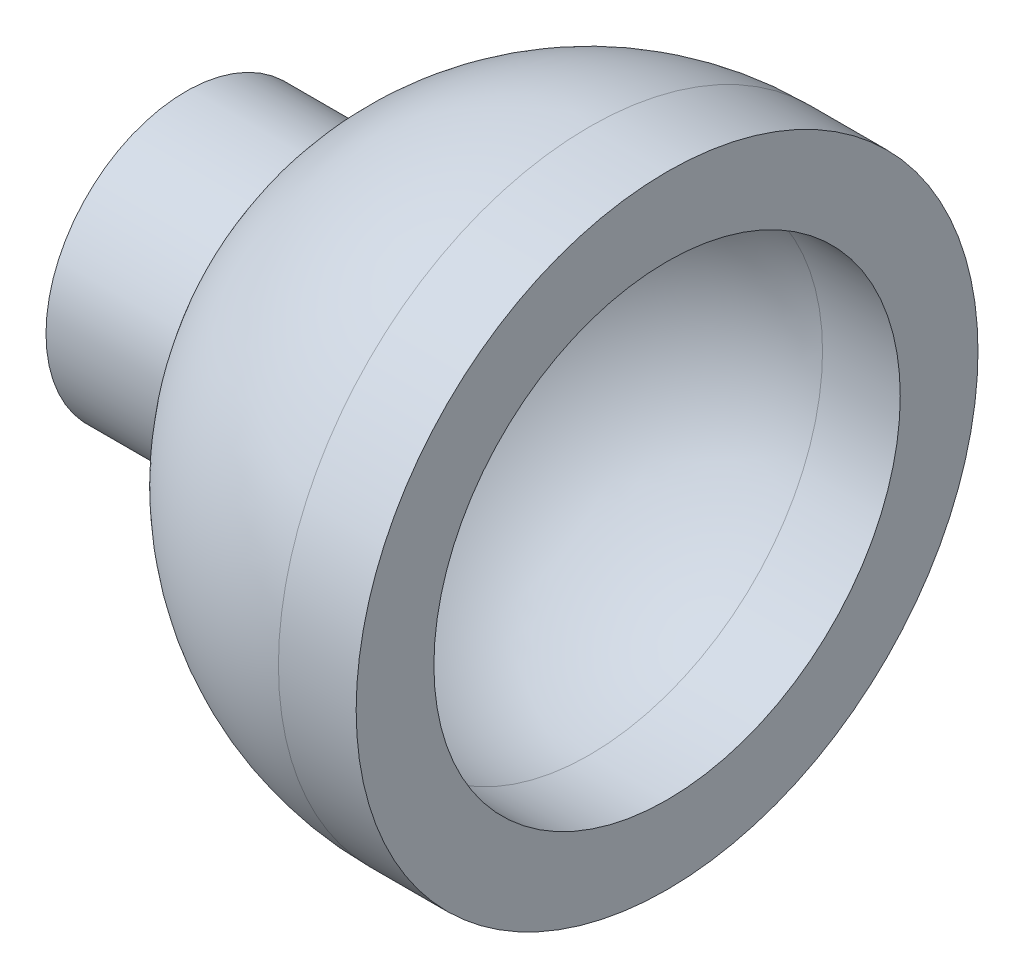
from build123d import *


with BuildPart() as part:
    # Sketch1 → Revolve1 (revolve)
    with BuildSketch(Plane.XY):
        with BuildLine():
            Line((-10.380317683, 1.6), (-7.838367177, 1.6))
            Line((-7.838367177, 1.6), (-5.782732918, 1.6))
            ThreePointArc((-5.782732918, 1.6), (-3.633180425, 4.774934555), (0, 6))
            Line((0, 6), (2, 6))
            Line((2, 6), (2, 8))
            Line((2, 8), (0, 8))
            ThreePointArc((0, 8), (-4.195235393, 6.811754546), (-7.14422844, 3.6))
            Line((-7.14422844, 3.6), (-10.380317683, 3.6))
            Line((-10.380317683, 3.6), (-10.380317683, 1.6))
        make_face()
    revolve(axis=Axis((-14.839725853, 0, 0), (1, 0, 0)))


solid = part.part
